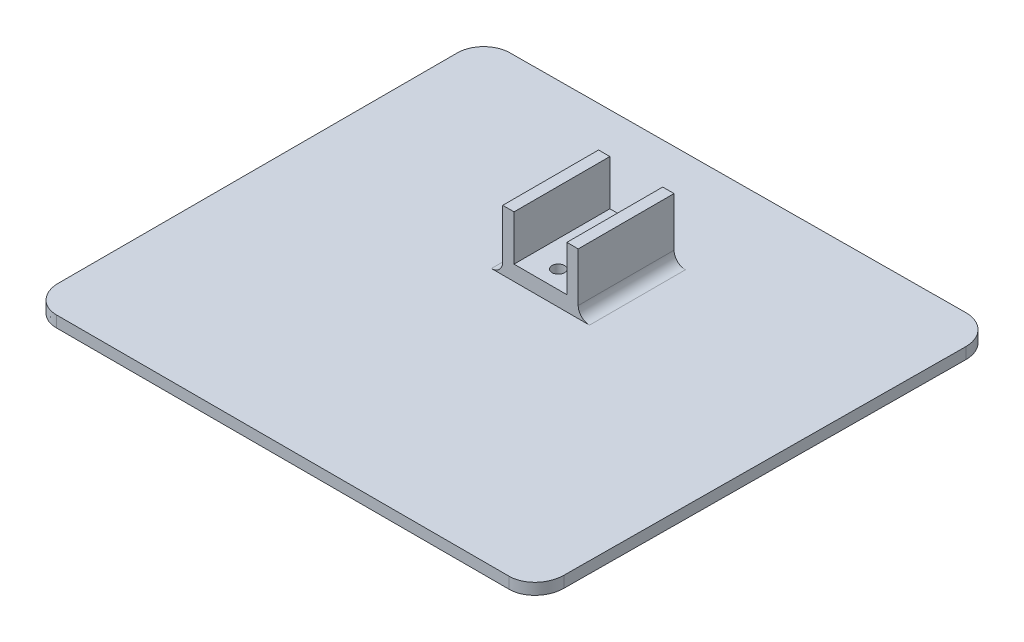
from build123d import *

# Parameters (mm, degrees)
SKETCH1_R           = 1.655864604
BOSS_EXTRUDE1_DEPTH = 3
SKETCH2_W           = 20
SKETCH2_H           = 25.399582392
SKETCH2_R           = 1.655864604
BOSS_EXTRUDE2_DEPTH = 16
SKETCH3_W           = 14
SKETCH3_H           = 30.433665038
CUT_EXTRUDE1_DEPTH  = 12
FILLET1_R           = 3
SKETCH4_R           = 3.655864604
CUT_EXTRUDE2_DEPTH  = 3


with BuildPart() as part:
    # Sketch1 → Boss-Extrude1 (new body)
    with BuildSketch(Plane(origin=(0, 0, 0), x_dir=(1, 0, 0), z_dir=(0, 1, 0))):
        with BuildLine():
            Line((-67.62365194, 48.899661457), (-67.62365194, -56.801447555))
            add(Edge.make_bspline(
                [(-67.62365194, -56.801447555), (-67.62365194, -57.576529056), (-67.408945412, -59.103174242), (-66.539947264, -61.00790182), (-65.334097821, -62.438503957), (-64.120247313, -63.394550402), (-62.546848101, -64.127219326), (-61.250619214, -64.324861548), (-60.62365194, -64.324861548)],
                knots=[0, 0, 0, 0, 0.25, 0.5, 0.625, 0.75, 0.875, 1, 1, 1, 1], degree=3))
            Line((-60.62365194, -64.324861548), (59.37634806, -64.324861548))
            add(Edge.make_bspline(
                [(59.37634806, -64.324861548), (59.996985006, -64.324861548), (61.275308456, -64.133359368), (62.856831905, -63.405567156), (64.077573394, -62.44733485), (65.282373866, -61.023465146), (66.158364103, -59.118925072), (66.37634806, -57.580964506), (66.37634806, -56.801447555)],
                knots=[0, 0, 0, 0, 0.125, 0.25, 0.375, 0.5, 0.75, 1, 1, 1, 1], degree=3))
            Line((66.37634806, -56.801447555), (67.164580452, 48.899661457))
            ThreePointArc((67.164580452, 48.899661457), (64.882544637, 54.407688605), (59.373759242, 56.687893419))
            Line((59.373759242, 56.687893419), (-60.62365194, 55.899661457))
            ThreePointArc((-60.62365194, 55.899661457), (-65.573399408, 53.849408926), (-67.62365194, 48.899661457))
        make_face()
        with Locations((-0.62365194, 23.293074001)):
            Circle(SKETCH1_R, mode=Mode.SUBTRACT)
        with Locations((-0.62365194, 8.677667421)):
            Circle(SKETCH1_R, mode=Mode.SUBTRACT)
    extrude(amount=BOSS_EXTRUDE1_DEPTH)

    # Sketch2 → Boss-Extrude2 (add)
    with BuildSketch(Plane(origin=(0, 3, 0), x_dir=(1, 0, 0), z_dir=(0, 1, 0))):
        with Locations((-0.62365194, 16.648607969)):
            Rectangle(SKETCH2_W, SKETCH2_H)
        with Locations((-0.62365194, 8.677667421)):
            Circle(SKETCH2_R, mode=Mode.SUBTRACT)
        with Locations((-0.62365194, 23.293074001)):
            Circle(SKETCH2_R, mode=Mode.SUBTRACT)
    extrude(amount=BOSS_EXTRUDE2_DEPTH)

    # Sketch3 → Cut-Extrude1 (cut)
    with BuildSketch(Plane(origin=(0, 19, 0), x_dir=(1, 0, 0), z_dir=(0, 1, 0))):
        with Locations((-0.62365194, 16.661700324)):
            Rectangle(SKETCH3_W, SKETCH3_H)
    extrude(amount=-CUT_EXTRUDE1_DEPTH, mode=Mode.SUBTRACT)

    # Fillet1
    fillet1_edges = [part.edges().sort_by_distance(p)[0] for p in [
        (-10.62365194, 3, -16.648607969),
        (9.37634806, 3, -16.648607969),
    ]]
    fillet(fillet1_edges, radius=FILLET1_R)

    # Sketch4 → Cut-Extrude2 (cut)
    with BuildSketch(Plane.XZ):
        with Locations((-0.62365194, -8.677667421)):
            Circle(SKETCH4_R)
        with Locations((-0.62365194, -23.293074001)):
            Circle(SKETCH4_R)
    extrude(amount=-CUT_EXTRUDE2_DEPTH, mode=Mode.SUBTRACT)


solid = part.part
